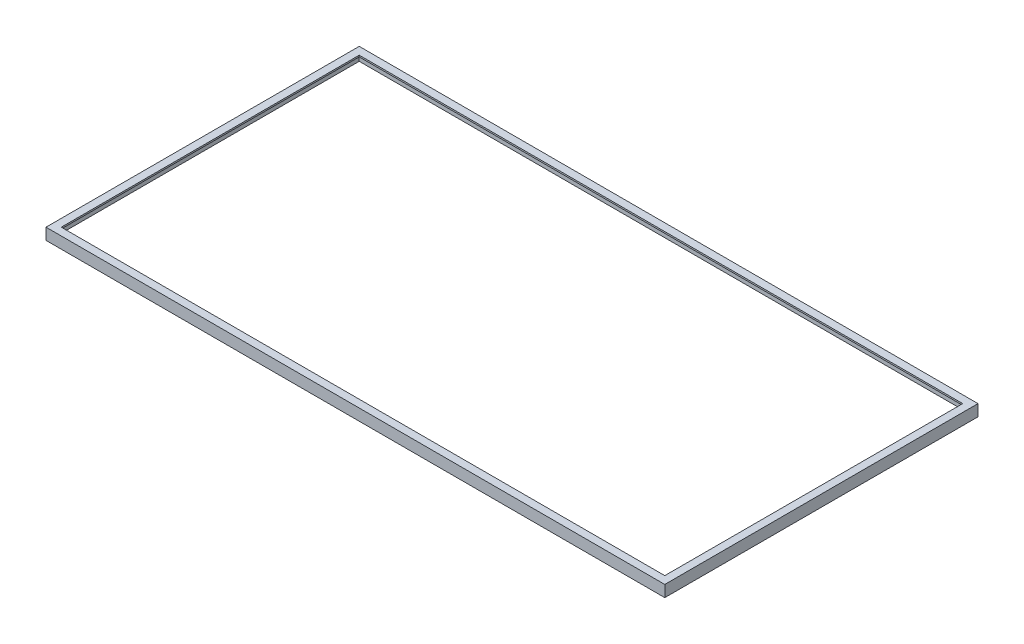
from build123d import *

# Parameters (mm, degrees)
SKETCH1_W           = 810
SKETCH1_H           = 410
BOSS_EXTRUDE1_DEPTH = 15
SHELL1_T            = -2
SKETCH2_W           = 790
SKETCH2_H           = 390
CUT_EXTRUDE1_DEPTH  = 15


with BuildPart() as part:
    # Sketch1 → Boss-Extrude1 (new body)
    with BuildSketch(Plane(origin=(0, 0, 0), x_dir=(1, 0, 0), z_dir=(0, 1, 0))):
        with Locations((405, 205)):
            Rectangle(SKETCH1_W, SKETCH1_H)
    extrude(amount=BOSS_EXTRUDE1_DEPTH)

    # Shell1
    shell1_openings = [part.faces().sort_by_distance(p)[0] for p in [
        (405, 0, -205),
    ]]
    offset(amount=SHELL1_T, openings=shell1_openings, kind=Kind.INTERSECTION)

    # Sketch2 → Cut-Extrude1 (cut)
    with BuildSketch(Plane(origin=(0, 15, 0), x_dir=(1, 0, 0), z_dir=(0, 1, 0))):
        with Locations((405, 205)):
            Rectangle(SKETCH2_W, SKETCH2_H)
    extrude(amount=-CUT_EXTRUDE1_DEPTH, mode=Mode.SUBTRACT)


solid = part.part
